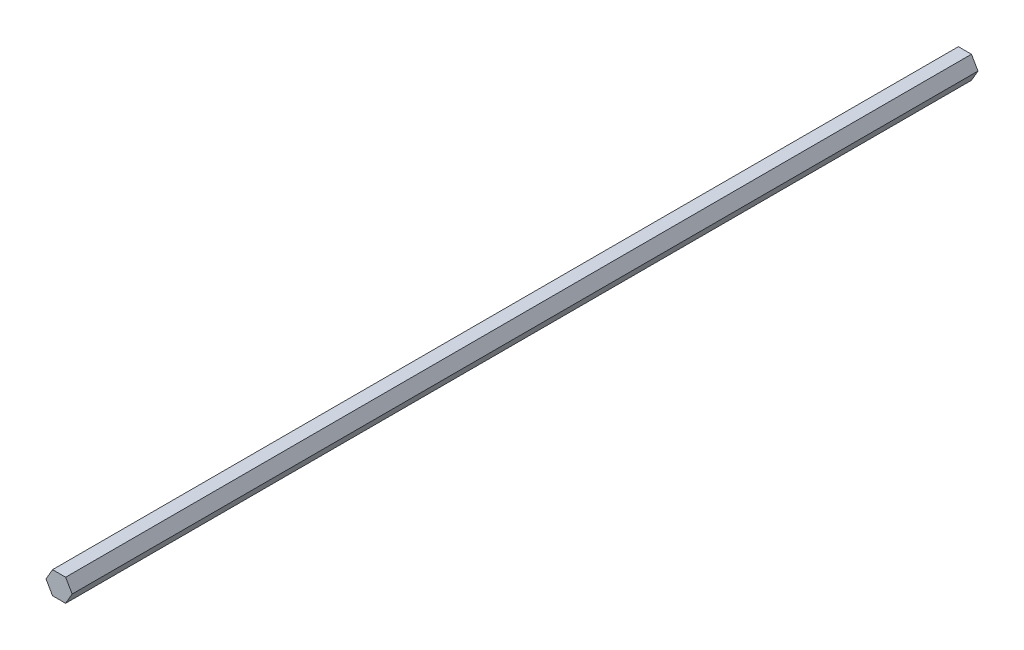
from build123d import *

# Parameters (mm, degrees)
BOSS_EXTRUDE1_DEPTH = 508


with BuildPart() as part:
    # Sketch1 → Boss-Extrude1 (new body)
    with BuildSketch(Plane.XY):
        Polygon((-3.666174209, 6.35), (-7.332348419, 0), (-3.666174209, -6.35), (3.666174209, -6.35), (7.332348419, 0), (3.666174209, 6.35), align=None)
    extrude(amount=BOSS_EXTRUDE1_DEPTH)


solid = part.part
